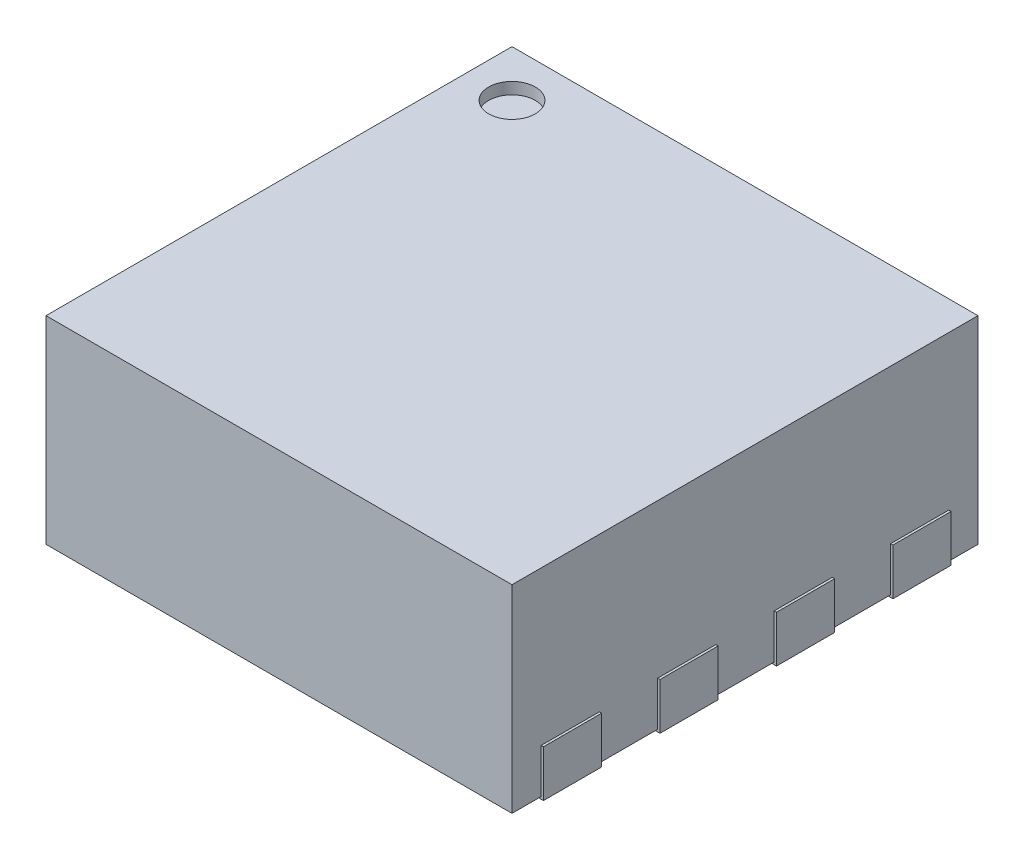
from build123d import *

# Parameters (mm, degrees)
SKETCH1_W             = 2
SKETCH1_H             = 2
BOSS_EXTRUDE1_DEPTH   = 0.85
BOSS_EXTRUDE2_START   = -0.01
SKETCH2_W             = 0.3
SKETCH2_H             = 0.25
BOSS_EXTRUDE2_DEPTH   = 0.2
BOSS_EXTRUDE2_2_DEPTH = 0.2
BOSS_EXTRUDE2_3_DEPTH = 0.2
BOSS_EXTRUDE2_4_DEPTH = 0.2
BOSS_EXTRUDE2_5_DEPTH = 0.2
BOSS_EXTRUDE2_6_DEPTH = 0.2
BOSS_EXTRUDE2_7_DEPTH = 0.2
BOSS_EXTRUDE2_8_DEPTH = 0.2
SKETCH3_R             = 0.1
CUT_EXTRUDE1_DEPTH    = 0.05


with BuildPart() as part:
    # Sketch1 → Boss-Extrude1 (new body)
    with BuildSketch(Plane(origin=(0, 0, 0), x_dir=(1, 0, 0), z_dir=(0, 1, 0))):
        Rectangle(SKETCH1_W, SKETCH1_H)
    extrude(amount=BOSS_EXTRUDE1_DEPTH)

    # Sketch3 → Cut-Extrude1 (cut)
    with BuildSketch(Plane(origin=(0, 0.85, 0), x_dir=(1, 0, 0), z_dir=(0, 1, 0))):
        with Locations((-0.8, 0.8)):
            Circle(SKETCH3_R)
    extrude(amount=-CUT_EXTRUDE1_DEPTH, mode=Mode.SUBTRACT)


with BuildPart() as body_2:
    # Sketch2 → Boss-Extrude2 (new body)
    with BuildSketch(Plane(origin=(0, 0, 0), x_dir=(1, 0, 0), z_dir=(0, 1, 0)).offset(BOSS_EXTRUDE2_START)):
        with Locations((-0.86, 0.25)):
            Rectangle(SKETCH2_W, SKETCH2_H)
    extrude(amount=BOSS_EXTRUDE2_DEPTH)


with BuildPart() as body_3:
    # Sketch2 → Boss-Extrude2 2 (new body)
    with BuildSketch(Plane(origin=(0, 0, 0), x_dir=(1, 0, 0), z_dir=(0, 1, 0)).offset(BOSS_EXTRUDE2_START)):
        with Locations((-0.86, 0.75)):
            Rectangle(SKETCH2_W, SKETCH2_H)
    extrude(amount=BOSS_EXTRUDE2_2_DEPTH)


with BuildPart() as body_4:
    # Sketch2 → Boss-Extrude2 3 (new body)
    with BuildSketch(Plane(origin=(0, 0, 0), x_dir=(1, 0, 0), z_dir=(0, 1, 0)).offset(BOSS_EXTRUDE2_START)):
        with Locations((-0.86, -0.25)):
            Rectangle(SKETCH2_W, SKETCH2_H)
    extrude(amount=BOSS_EXTRUDE2_3_DEPTH)


with BuildPart() as body_5:
    # Sketch2 → Boss-Extrude2 4 (new body)
    with BuildSketch(Plane(origin=(0, 0, 0), x_dir=(1, 0, 0), z_dir=(0, 1, 0)).offset(BOSS_EXTRUDE2_START)):
        with Locations((-0.86, -0.75)):
            Rectangle(SKETCH2_W, SKETCH2_H)
    extrude(amount=BOSS_EXTRUDE2_4_DEPTH)


with BuildPart() as body_6:
    # Sketch2 → Boss-Extrude2 5 (new body)
    with BuildSketch(Plane(origin=(0, 0, 0), x_dir=(1, 0, 0), z_dir=(0, 1, 0)).offset(BOSS_EXTRUDE2_START)):
        with Locations((0.86, -0.75)):
            Rectangle(SKETCH2_W, SKETCH2_H)
    extrude(amount=BOSS_EXTRUDE2_5_DEPTH)


with BuildPart() as body_7:
    # Sketch2 → Boss-Extrude2 6 (new body)
    with BuildSketch(Plane(origin=(0, 0, 0), x_dir=(1, 0, 0), z_dir=(0, 1, 0)).offset(BOSS_EXTRUDE2_START)):
        with Locations((0.86, -0.25)):
            Rectangle(SKETCH2_W, SKETCH2_H)
    extrude(amount=BOSS_EXTRUDE2_6_DEPTH)


with BuildPart() as body_8:
    # Sketch2 → Boss-Extrude2 7 (new body)
    with BuildSketch(Plane(origin=(0, 0, 0), x_dir=(1, 0, 0), z_dir=(0, 1, 0)).offset(BOSS_EXTRUDE2_START)):
        with Locations((0.86, 0.75)):
            Rectangle(SKETCH2_W, SKETCH2_H)
    extrude(amount=BOSS_EXTRUDE2_7_DEPTH)


with BuildPart() as body_9:
    # Sketch2 → Boss-Extrude2 8 (new body)
    with BuildSketch(Plane(origin=(0, 0, 0), x_dir=(1, 0, 0), z_dir=(0, 1, 0)).offset(BOSS_EXTRUDE2_START)):
        with Locations((0.86, 0.25)):
            Rectangle(SKETCH2_W, SKETCH2_H)
    extrude(amount=BOSS_EXTRUDE2_8_DEPTH)


solid = Compound([part.part, body_2.part, body_3.part, body_4.part, body_5.part, body_6.part, body_7.part, body_8.part, body_9.part])
